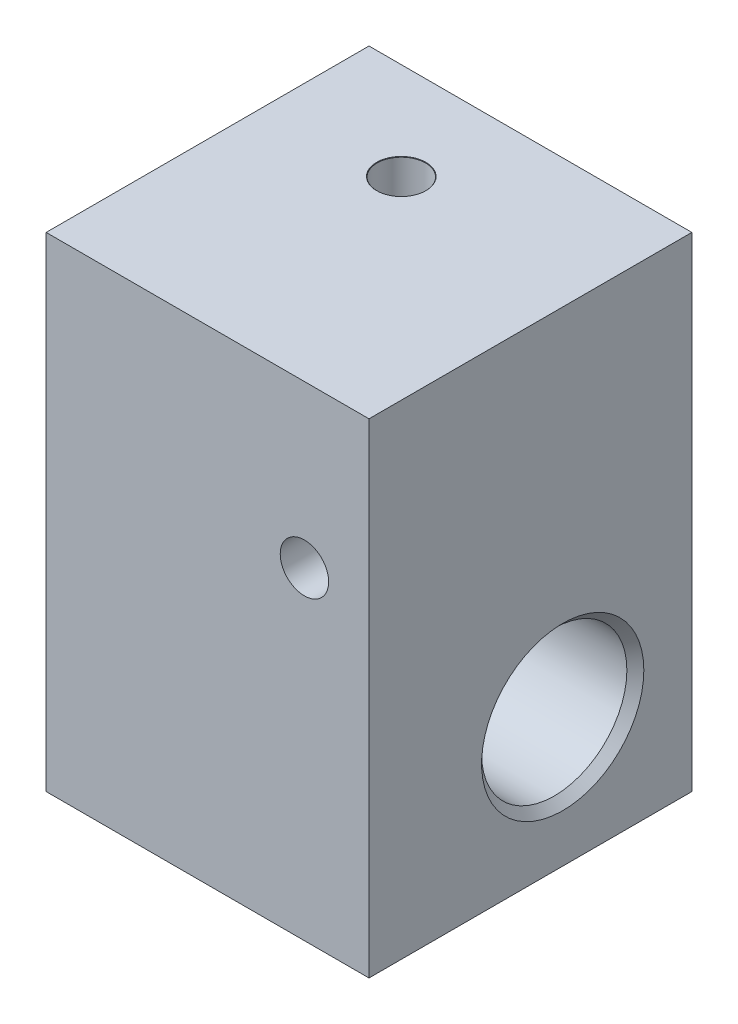
from build123d import *

# Parameters (mm, degrees)
SKETCH1_W                        = 20
SKETCH1_H                        = 20
BOSS_EXTRUDE1_DEPTH              = 30
F_3_0MM_DOWEL_HOLE1_D            = 3
F_3_0MM_DOWEL_HOLE1_DEPTH        = 20
F_3_0MM_DOWEL_HOLE1_CSINK_D      = 3.05
F_3_0MM_DOWEL_HOLE1_CSINK_ANGLE  = 90
F_3_0MM_DOWEL_HOLE1_TIP          = 0.901290929
F_3_0MM_DOWEL_HOLE2_D            = 3
F_3_0MM_DOWEL_HOLE2_DEPTH        = 12
F_3_0MM_DOWEL_HOLE2_CSINK_D      = 3.05
F_3_0MM_DOWEL_HOLE2_CSINK_ANGLE  = 90
F_3_0MM_DOWEL_HOLE2_TIP          = 0.901290929
F_3_0MM_DOWEL_HOLE3_D            = 3
F_3_0MM_DOWEL_HOLE3_DEPTH        = 20
F_3_0MM_DOWEL_HOLE3_CSINK_D      = 3.05
F_3_0MM_DOWEL_HOLE3_CSINK_ANGLE  = 90
F_3_0MM_DOWEL_HOLE3_TIP          = 0.901290929
F_10_0MM_DOWEL_HOLE1_D           = 9
F_10_0MM_DOWEL_HOLE1_DEPTH       = 17
F_10_0MM_DOWEL_HOLE1_CSINK_D     = 10.05
F_10_0MM_DOWEL_HOLE1_CSINK_ANGLE = 90
F_10_0MM_DOWEL_HOLE1_TIP         = 2.703872786


with BuildPart() as part:
    # Sketch1 → Boss-Extrude1 (new body)
    with BuildSketch(Plane(origin=(0, 0, 0), x_dir=(1, 0, 0), z_dir=(0, 1, 0))):
        with Locations((10, -8.099538279)):
            Rectangle(SKETCH1_W, SKETCH1_H)
    extrude(amount=BOSS_EXTRUDE1_DEPTH)

    # Ø3.0mm Dowel Hole1
    with Locations(Plane(origin=(0, 0, -1.900461721), x_dir=(-1, 0, 0), z_dir=(0, 0, -1))):
        with Locations((-16, 20)):
            CounterSinkHole(F_3_0MM_DOWEL_HOLE1_D / 2, F_3_0MM_DOWEL_HOLE1_CSINK_D / 2, depth=F_3_0MM_DOWEL_HOLE1_DEPTH, counter_sink_angle=F_3_0MM_DOWEL_HOLE1_CSINK_ANGLE)
            with Locations((0, 0, -(F_3_0MM_DOWEL_HOLE1_DEPTH + F_3_0MM_DOWEL_HOLE1_TIP / 2))):  # 118° drill point
                Cone(0, F_3_0MM_DOWEL_HOLE1_D / 2, F_3_0MM_DOWEL_HOLE1_TIP, mode=Mode.SUBTRACT)

    # Ø3.0mm Dowel Hole2
    with Locations(Plane.ZY):
        with Locations((10.099538279, 20)):
            CounterSinkHole(F_3_0MM_DOWEL_HOLE2_D / 2, F_3_0MM_DOWEL_HOLE2_CSINK_D / 2, depth=F_3_0MM_DOWEL_HOLE2_DEPTH, counter_sink_angle=F_3_0MM_DOWEL_HOLE2_CSINK_ANGLE)
            with Locations((0, 0, -(F_3_0MM_DOWEL_HOLE2_DEPTH + F_3_0MM_DOWEL_HOLE2_TIP / 2))):  # 118° drill point
                Cone(0, F_3_0MM_DOWEL_HOLE2_D / 2, F_3_0MM_DOWEL_HOLE2_TIP, mode=Mode.SUBTRACT)

    # Ø3.0mm Dowel Hole3
    with Locations(Plane(origin=(0, 30, 0), x_dir=(1, 0, 0), z_dir=(0, 1, 0))):
        with Locations((8, -4.099538279)):
            CounterSinkHole(F_3_0MM_DOWEL_HOLE3_D / 2, F_3_0MM_DOWEL_HOLE3_CSINK_D / 2, depth=F_3_0MM_DOWEL_HOLE3_DEPTH, counter_sink_angle=F_3_0MM_DOWEL_HOLE3_CSINK_ANGLE)
            with Locations((0, 0, -(F_3_0MM_DOWEL_HOLE3_DEPTH + F_3_0MM_DOWEL_HOLE3_TIP / 2))):  # 118° drill point
                Cone(0, F_3_0MM_DOWEL_HOLE3_D / 2, F_3_0MM_DOWEL_HOLE3_TIP, mode=Mode.SUBTRACT)

    # Ø10.0mm Dowel Hole1
    with Locations(Plane(origin=(20, 0, 0), x_dir=(0, 0, -1), z_dir=(1, 0, 0))):
        with Locations((-6.099538279, 8)):
            CounterSinkHole(F_10_0MM_DOWEL_HOLE1_D / 2, F_10_0MM_DOWEL_HOLE1_CSINK_D / 2, depth=F_10_0MM_DOWEL_HOLE1_DEPTH, counter_sink_angle=F_10_0MM_DOWEL_HOLE1_CSINK_ANGLE)
            with Locations((0, 0, -(F_10_0MM_DOWEL_HOLE1_DEPTH + F_10_0MM_DOWEL_HOLE1_TIP / 2))):  # 118° drill point
                Cone(0, F_10_0MM_DOWEL_HOLE1_D / 2, F_10_0MM_DOWEL_HOLE1_TIP, mode=Mode.SUBTRACT)


solid = part.part
